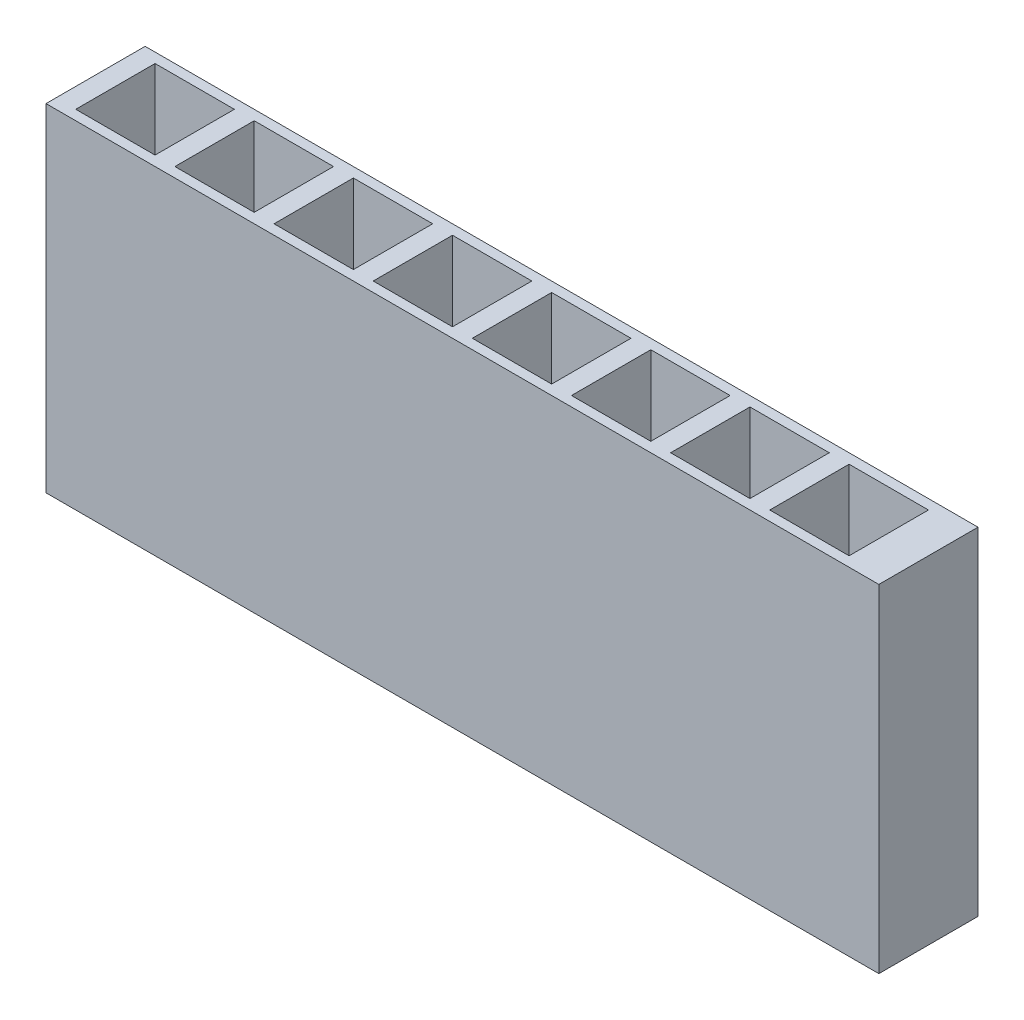
from build123d import *

# Parameters (mm, degrees)
SKETCH1_W           = 21
SKETCH1_H           = 2.5
BOSS_EXTRUDE1_DEPTH = 8.5
SKETCH2_W           = 2
SKETCH2_H           = 2
CUT_EXTRUDE1_DEPTH  = 5


with BuildPart() as part:
    # Sketch1 → Boss-Extrude1 (new body)
    with BuildSketch(Plane(origin=(0, 0, 0), x_dir=(1, 0, 0), z_dir=(0, 1, 0))):
        Rectangle(SKETCH1_W, SKETCH1_H)
    extrude(amount=BOSS_EXTRUDE1_DEPTH)

    # Sketch2 → Cut-Extrude1 (cut)
    with BuildSketch(Plane(origin=(0, 8.5, 0), x_dir=(1, 0, 0), z_dir=(0, 1, 0))):
        with Locations((-6.5, 0)):
            Rectangle(SKETCH2_W, SKETCH2_H)
        with Locations((-9, 0)):
            Rectangle(SKETCH2_W, SKETCH2_H)
        with Locations((-4, 0)):
            Rectangle(SKETCH2_W, SKETCH2_H)
        with Locations((-1.5, 0)):
            Rectangle(SKETCH2_W, SKETCH2_H)
        with Locations((1, 0)):
            Rectangle(SKETCH2_W, SKETCH2_H)
        with Locations((3.5, 0)):
            Rectangle(SKETCH2_W, SKETCH2_H)
        with Locations((6, 0)):
            Rectangle(SKETCH2_W, SKETCH2_H)
        with Locations((8.5, 0)):
            Rectangle(SKETCH2_W, SKETCH2_H)
    extrude(amount=-CUT_EXTRUDE1_DEPTH, mode=Mode.SUBTRACT)


solid = part.part
